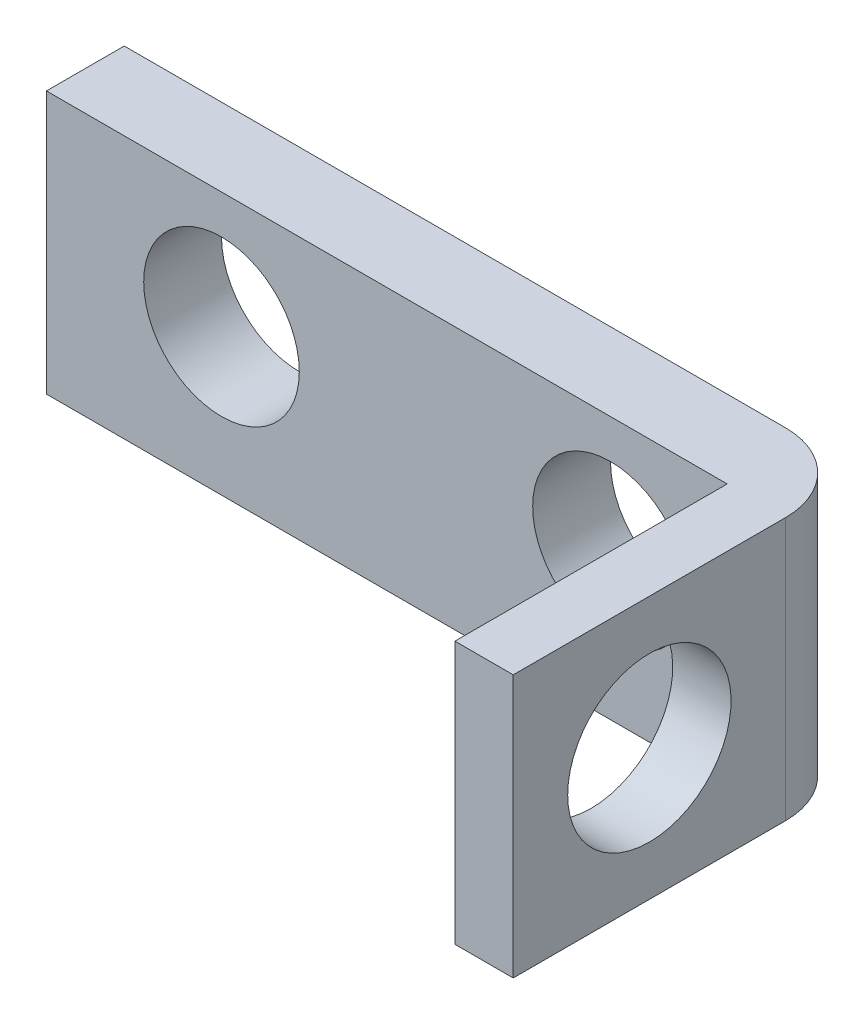
from build123d import *

# Parameters (mm, degrees)
ESQUISSE1_W             = 19
ESQUISSE1_H             = 6.75
BOSS_EXTRU_1_DEPTH      = 2
ESQUISSE4_R             = 2
ENL_V_MAT_EXTRU_1_DEPTH = 10
ESQUISSE6_W             = 1.5
ESQUISSE6_H             = 6.75
BOSS_EXTRU_2_DEPTH      = 7
CONG_1_R                = 2
ESQUISSE7_R             = 2.1
ENL_V_MAT_EXTRU_2_DEPTH = 3


with BuildPart() as part:
    # Esquisse1 → Boss.-Extru.1 (new body)
    with BuildSketch(Plane.XY):
        with Locations((9.5, -3.375)):
            Rectangle(ESQUISSE1_W, ESQUISSE1_H)
    extrude(amount=BOSS_EXTRU_1_DEPTH)

    # Esquisse4 → Enlèv. mat.-Extru.1 (cut)
    with BuildSketch(Plane(origin=(0, 0, 0), x_dir=(-1, 0, 0), z_dir=(0, 0, -1))):
        with Locations((-14.5, -3)):
            Circle(ESQUISSE4_R)
        with Locations((-4.5, -3)):
            Circle(ESQUISSE4_R)
    extrude(amount=-ENL_V_MAT_EXTRU_1_DEPTH, mode=Mode.SUBTRACT)

    # Esquisse6 → Boss.-Extru.2 (add)
    with BuildSketch(Plane.XY.offset(2)):
        with Locations((18.25, -3.375)):
            Rectangle(ESQUISSE6_W, ESQUISSE6_H)
    extrude(amount=BOSS_EXTRU_2_DEPTH)

    # Congé1
    cong_1_edges = [part.edges().sort_by_distance(p)[0] for p in [
        (19, -3.375, 0),
    ]]
    fillet(cong_1_edges, radius=CONG_1_R)

    # Esquisse7 → Enlèv. mat.-Extru.2 (cut)
    with BuildSketch(Plane.ZY.offset(-17.5)):
        with Locations((5.5, -3.375)):
            Circle(ESQUISSE7_R)
    extrude(amount=-ENL_V_MAT_EXTRU_2_DEPTH, mode=Mode.SUBTRACT)


solid = part.part
